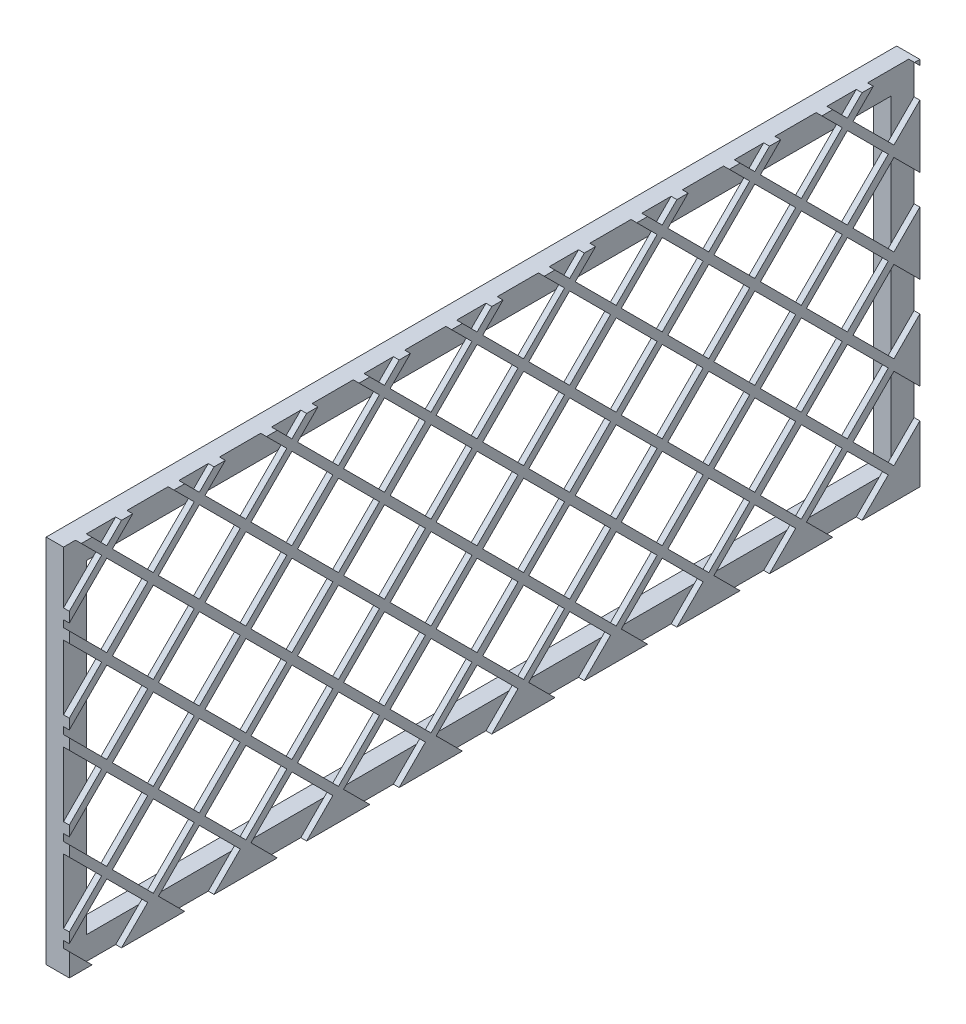
from build123d import *

# Parameters (mm, degrees)
SKETCH1_W           = 466.725
SKETCH1_H           = 203.2
SKETCH1_W_2         = 441.325
SKETCH1_H_2         = 177.8
BOSS_EXTRUDE1_DEPTH = 12.7
SKETCH2_W           = 441.325
SKETCH2_H           = 177.8
BOSS_EXTRUDE2_DEPTH = 3.175
CUT_EXTRUDE1_DEPTH  = 3.175


with BuildPart() as part:
    # Sketch1 → Boss-Extrude1 (new body)
    with BuildSketch(Plane(origin=(0, 0, 0), x_dir=(0, 0, -1), z_dir=(1, 0, 0))):
        with Locations((134.9375, -104.913043478)):
            Rectangle(SKETCH1_W, SKETCH1_H)
        with Locations((134.9375, -104.913043478)):
            Rectangle(SKETCH1_W_2, SKETCH1_H_2, mode=Mode.SUBTRACT)
    extrude(amount=BOSS_EXTRUDE1_DEPTH)

    # Sketch2 → Boss-Extrude2 (add)
    with BuildSketch(Plane(origin=(12.7, 0, 0), x_dir=(0, 0, -1), z_dir=(1, 0, 0))):
        with Locations((134.9375, -104.913043478)):
            Rectangle(SKETCH2_W, SKETCH2_H)
    extrude(amount=-BOSS_EXTRUDE2_DEPTH)

    # Sketch3 → Cut-Extrude1 (cut)
    with BuildSketch(Plane.ZY.offset(-9.525)):
        Polygon((-350.98474355, 163.475506724), (-328.534103247, 185.926147027), (-306.083462944, 163.475506724), (-328.534103247, 141.024866421), align=None)
        Polygon((-354.077856822, 211.182393452), (-331.627216519, 188.731753149), (-354.077856822, 166.281112846), (-376.528497125, 188.731753149), align=None)
        Polygon((-300.18474355, 163.475506724), (-277.734103247, 185.926147027), (-255.283462944, 163.475506724), (-277.734103247, 141.024866421), align=None)
        Polygon((-280.827216519, 188.731753149), (-303.277856822, 166.281112846), (-325.728497125, 188.731753149), (-303.277856822, 211.182393452), align=None)
        Polygon((-249.38474355, 163.475506724), (-226.934103247, 185.926147027), (-204.483462944, 163.475506724), (-226.934103247, 141.024866421), align=None)
        Polygon((-230.027216519, 188.731753149), (-252.477856822, 166.281112846), (-274.928497125, 188.731753149), (-252.477856822, 211.182393452), align=None)
        Polygon((-198.58474355, 163.475506724), (-176.134103247, 185.926147027), (-153.683462944, 163.475506724), (-176.134103247, 141.024866421), align=None)
        Polygon((-179.227216519, 188.731753149), (-201.677856822, 166.281112846), (-224.128497125, 188.731753149), (-201.677856822, 211.182393452), align=None)
        Polygon((-147.78474355, 163.475506724), (-125.334103247, 185.926147027), (-102.883462944, 163.475506724), (-125.334103247, 141.024866421), align=None)
        Polygon((-128.427216519, 188.731753149), (-150.877856822, 166.281112846), (-173.328497125, 188.731753149), (-150.877856822, 211.182393452), align=None)
        Polygon((-96.98474355, 163.475506724), (-74.534103247, 185.926147027), (-52.083462944, 163.475506724), (-74.534103247, 141.024866421), align=None)
        Polygon((-77.627216519, 188.731753149), (-100.077856822, 166.281112846), (-122.528497125, 188.731753149), (-100.077856822, 211.182393452), align=None)
        Polygon((-46.18474355, 163.475506724), (-23.734103247, 185.926147027), (-1.283462944, 163.475506724), (-23.734103247, 141.024866421), align=None)
        Polygon((-26.827216519, 188.731753149), (-49.277856822, 166.281112846), (-71.728497125, 188.731753149), (-49.277856822, 211.182393452), align=None)
        Polygon((4.61525645, 163.475506724), (27.065896753, 185.926147027), (49.516537056, 163.475506724), (27.065896753, 141.024866421), align=None)
        Polygon((23.972783481, 188.731753149), (1.522143178, 166.281112846), (-20.928497125, 188.731753149), (1.522143178, 211.182393452), align=None)
        Polygon((55.41525645, 163.475506724), (77.865896753, 185.926147027), (100.316537056, 163.475506724), (77.865896753, 141.024866421), align=None)
        Polygon((74.772783481, 188.731753149), (52.322143178, 166.281112846), (29.871502875, 188.731753149), (52.322143178, 211.182393452), align=None)
        Polygon((106.21525645, 163.475506724), (128.665896753, 185.926147027), (151.116537056, 163.475506724), (128.665896753, 141.024866421), align=None)
        Polygon((125.572783481, 188.731753149), (103.122143178, 166.281112846), (80.671502875, 188.731753149), (103.122143178, 211.182393452), align=None)
        Polygon((157.01525645, 163.475506724), (179.465896753, 185.926147027), (201.916537056, 163.475506724), (179.465896753, 141.024866421), align=None)
        Polygon((176.372783481, 188.731753149), (153.922143178, 166.281112846), (131.471502875, 188.731753149), (153.922143178, 211.182393452), align=None)
        Polygon((207.81525645, 163.475506724), (230.265896753, 185.926147027), (252.716537056, 163.475506724), (230.265896753, 141.024866421), align=None)
        Polygon((227.172783481, 188.731753149), (204.722143178, 166.281112846), (182.271502875, 188.731753149), (204.722143178, 211.182393452), align=None)
        Polygon((258.61525645, 163.475506724), (281.065896753, 185.926147027), (303.516537056, 163.475506724), (281.065896753, 141.024866421), align=None)
        Polygon((277.972783481, 188.731753149), (255.522143178, 166.281112846), (233.071502875, 188.731753149), (255.522143178, 211.182393452), align=None)
        Polygon((-300.18474355, 112.675506724), (-277.734103247, 135.126147027), (-255.283462944, 112.675506724), (-277.734103247, 90.224866421), align=None)
        Polygon((-280.827216519, 137.931753149), (-303.277856822, 115.481112846), (-325.728497125, 137.931753149), (-303.277856822, 160.382393452), align=None)
        Polygon((-249.38474355, 112.675506724), (-226.934103247, 135.126147027), (-204.483462944, 112.675506724), (-226.934103247, 90.224866421), align=None)
        Polygon((-230.027216519, 137.931753149), (-252.477856822, 115.481112846), (-274.928497125, 137.931753149), (-252.477856822, 160.382393452), align=None)
        Polygon((-198.58474355, 112.675506724), (-176.134103247, 135.126147027), (-153.683462944, 112.675506724), (-176.134103247, 90.224866421), align=None)
        Polygon((-179.227216519, 137.931753149), (-201.677856822, 115.481112846), (-224.128497125, 137.931753149), (-201.677856822, 160.382393452), align=None)
        Polygon((-147.78474355, 112.675506724), (-125.334103247, 135.126147027), (-102.883462944, 112.675506724), (-125.334103247, 90.224866421), align=None)
        Polygon((-128.427216519, 137.931753149), (-150.877856822, 115.481112846), (-173.328497125, 137.931753149), (-150.877856822, 160.382393452), align=None)
        Polygon((-96.98474355, 112.675506724), (-74.534103247, 135.126147027), (-52.083462944, 112.675506724), (-74.534103247, 90.224866421), align=None)
        Polygon((-77.627216519, 137.931753149), (-100.077856822, 115.481112846), (-122.528497125, 137.931753149), (-100.077856822, 160.382393452), align=None)
        Polygon((-46.18474355, 112.675506724), (-23.734103247, 135.126147027), (-1.283462944, 112.675506724), (-23.734103247, 90.224866421), align=None)
        Polygon((-26.827216519, 137.931753149), (-49.277856822, 115.481112846), (-71.728497125, 137.931753149), (-49.277856822, 160.382393452), align=None)
        Polygon((4.61525645, 112.675506724), (27.065896753, 135.126147027), (49.516537056, 112.675506724), (27.065896753, 90.224866421), align=None)
        Polygon((23.972783481, 137.931753149), (1.522143178, 115.481112846), (-20.928497125, 137.931753149), (1.522143178, 160.382393452), align=None)
        Polygon((55.41525645, 112.675506724), (77.865896753, 135.126147027), (100.316537056, 112.675506724), (77.865896753, 90.224866421), align=None)
        Polygon((74.772783481, 137.931753149), (52.322143178, 115.481112846), (29.871502875, 137.931753149), (52.322143178, 160.382393452), align=None)
        Polygon((106.21525645, 112.675506724), (128.665896753, 135.126147027), (151.116537056, 112.675506724), (128.665896753, 90.224866421), align=None)
        Polygon((125.572783481, 137.931753149), (103.122143178, 115.481112846), (80.671502875, 137.931753149), (103.122143178, 160.382393452), align=None)
        Polygon((157.01525645, 112.675506724), (179.465896753, 135.126147027), (201.916537056, 112.675506724), (179.465896753, 90.224866421), align=None)
        Polygon((176.372783481, 137.931753149), (153.922143178, 115.481112846), (131.471502875, 137.931753149), (153.922143178, 160.382393452), align=None)
        Polygon((207.81525645, 112.675506724), (230.265896753, 135.126147027), (252.716537056, 112.675506724), (230.265896753, 90.224866421), align=None)
        Polygon((227.172783481, 137.931753149), (204.722143178, 115.481112846), (182.271502875, 137.931753149), (204.722143178, 160.382393452), align=None)
        Polygon((258.61525645, 112.675506724), (281.065896753, 135.126147027), (303.516537056, 112.675506724), (281.065896753, 90.224866421), align=None)
        Polygon((277.972783481, 137.931753149), (255.522143178, 115.481112846), (233.071502875, 137.931753149), (255.522143178, 160.382393452), align=None)
        Polygon((-300.18474355, 61.875506724), (-277.734103247, 84.326147027), (-255.283462944, 61.875506724), (-277.734103247, 39.424866421), align=None)
        Polygon((-280.827216519, 87.131753149), (-303.277856822, 64.681112846), (-325.728497125, 87.131753149), (-303.277856822, 109.582393452), align=None)
        Polygon((-249.38474355, 61.875506724), (-226.934103247, 84.326147027), (-204.483462944, 61.875506724), (-226.934103247, 39.424866421), align=None)
        Polygon((-230.027216519, 87.131753149), (-252.477856822, 64.681112846), (-274.928497125, 87.131753149), (-252.477856822, 109.582393452), align=None)
        Polygon((-198.58474355, 61.875506724), (-176.134103247, 84.326147027), (-153.683462944, 61.875506724), (-176.134103247, 39.424866421), align=None)
        Polygon((-179.227216519, 87.131753149), (-201.677856822, 64.681112846), (-224.128497125, 87.131753149), (-201.677856822, 109.582393452), align=None)
        Polygon((-147.78474355, 61.875506724), (-125.334103247, 84.326147027), (-102.883462944, 61.875506724), (-125.334103247, 39.424866421), align=None)
        Polygon((-128.427216519, 87.131753149), (-150.877856822, 64.681112846), (-173.328497125, 87.131753149), (-150.877856822, 109.582393452), align=None)
        Polygon((-96.98474355, 61.875506724), (-74.534103247, 84.326147027), (-52.083462944, 61.875506724), (-74.534103247, 39.424866421), align=None)
        Polygon((-77.627216519, 87.131753149), (-100.077856822, 64.681112846), (-122.528497125, 87.131753149), (-100.077856822, 109.582393452), align=None)
        Polygon((-46.18474355, 61.875506724), (-23.734103247, 84.326147027), (-1.283462944, 61.875506724), (-23.734103247, 39.424866421), align=None)
        Polygon((-26.827216519, 87.131753149), (-49.277856822, 64.681112846), (-71.728497125, 87.131753149), (-49.277856822, 109.582393452), align=None)
        Polygon((4.61525645, 61.875506724), (27.065896753, 84.326147027), (49.516537056, 61.875506724), (27.065896753, 39.424866421), align=None)
        Polygon((23.972783481, 87.131753149), (1.522143178, 64.681112846), (-20.928497125, 87.131753149), (1.522143178, 109.582393452), align=None)
        Polygon((55.41525645, 61.875506724), (77.865896753, 84.326147027), (100.316537056, 61.875506724), (77.865896753, 39.424866421), align=None)
        Polygon((74.772783481, 87.131753149), (52.322143178, 64.681112846), (29.871502875, 87.131753149), (52.322143178, 109.582393452), align=None)
        Polygon((106.21525645, 61.875506724), (128.665896753, 84.326147027), (151.116537056, 61.875506724), (128.665896753, 39.424866421), align=None)
        Polygon((125.572783481, 87.131753149), (103.122143178, 64.681112846), (80.671502875, 87.131753149), (103.122143178, 109.582393452), align=None)
        Polygon((157.01525645, 61.875506724), (179.465896753, 84.326147027), (201.916537056, 61.875506724), (179.465896753, 39.424866421), align=None)
        Polygon((176.372783481, 87.131753149), (153.922143178, 64.681112846), (131.471502875, 87.131753149), (153.922143178, 109.582393452), align=None)
        Polygon((207.81525645, 61.875506724), (230.265896753, 84.326147027), (252.716537056, 61.875506724), (230.265896753, 39.424866421), align=None)
        Polygon((227.172783481, 87.131753149), (204.722143178, 64.681112846), (182.271502875, 87.131753149), (204.722143178, 109.582393452), align=None)
        Polygon((258.61525645, 61.875506724), (281.065896753, 84.326147027), (303.516537056, 61.875506724), (281.065896753, 39.424866421), align=None)
        Polygon((277.972783481, 87.131753149), (255.522143178, 64.681112846), (233.071502875, 87.131753149), (255.522143178, 109.582393452), align=None)
        Polygon((-300.18474355, 11.075506724), (-277.734103247, 33.526147027), (-255.283462944, 11.075506724), (-277.734103247, -11.375133579), align=None)
        Polygon((-280.827216519, 36.331753149), (-303.277856822, 13.881112846), (-325.728497125, 36.331753149), (-303.277856822, 58.782393452), align=None)
        Polygon((-249.38474355, 11.075506724), (-226.934103247, 33.526147027), (-204.483462944, 11.075506724), (-226.934103247, -11.375133579), align=None)
        Polygon((-230.027216519, 36.331753149), (-252.477856822, 13.881112846), (-274.928497125, 36.331753149), (-252.477856822, 58.782393452), align=None)
        Polygon((-198.58474355, 11.075506724), (-176.134103247, 33.526147027), (-153.683462944, 11.075506724), (-176.134103247, -11.375133579), align=None)
        Polygon((-179.227216519, 36.331753149), (-201.677856822, 13.881112846), (-224.128497125, 36.331753149), (-201.677856822, 58.782393452), align=None)
        Polygon((-147.78474355, 11.075506724), (-125.334103247, 33.526147027), (-102.883462944, 11.075506724), (-125.334103247, -11.375133579), align=None)
        Polygon((-128.427216519, 36.331753149), (-150.877856822, 13.881112846), (-173.328497125, 36.331753149), (-150.877856822, 58.782393452), align=None)
        Polygon((-96.98474355, 11.075506724), (-74.534103247, 33.526147027), (-52.083462944, 11.075506724), (-74.534103247, -11.375133579), align=None)
        Polygon((-77.627216519, 36.331753149), (-100.077856822, 13.881112846), (-122.528497125, 36.331753149), (-100.077856822, 58.782393452), align=None)
        Polygon((-46.18474355, 11.075506724), (-23.734103247, 33.526147027), (-1.283462944, 11.075506724), (-23.734103247, -11.375133579), align=None)
        Polygon((-26.827216519, 36.331753149), (-49.277856822, 13.881112846), (-71.728497125, 36.331753149), (-49.277856822, 58.782393452), align=None)
        Polygon((4.61525645, 11.075506724), (27.065896753, 33.526147027), (49.516537056, 11.075506724), (27.065896753, -11.375133579), align=None)
        Polygon((23.972783481, 36.331753149), (1.522143178, 13.881112846), (-20.928497125, 36.331753149), (1.522143178, 58.782393452), align=None)
        Polygon((55.41525645, 11.075506724), (77.865896753, 33.526147027), (100.316537056, 11.075506724), (77.865896753, -11.375133579), align=None)
        Polygon((74.772783481, 36.331753149), (52.322143178, 13.881112846), (29.871502875, 36.331753149), (52.322143178, 58.782393452), align=None)
        Polygon((106.21525645, 11.075506724), (128.665896753, 33.526147027), (151.116537056, 11.075506724), (128.665896753, -11.375133579), align=None)
        Polygon((125.572783481, 36.331753149), (103.122143178, 13.881112846), (80.671502875, 36.331753149), (103.122143178, 58.782393452), align=None)
        Polygon((157.01525645, 11.075506724), (179.465896753, 33.526147027), (201.916537056, 11.075506724), (179.465896753, -11.375133579), align=None)
        Polygon((176.372783481, 36.331753149), (153.922143178, 13.881112846), (131.471502875, 36.331753149), (153.922143178, 58.782393452), align=None)
        Polygon((207.81525645, 11.075506724), (230.265896753, 33.526147027), (252.716537056, 11.075506724), (230.265896753, -11.375133579), align=None)
        Polygon((227.172783481, 36.331753149), (204.722143178, 13.881112846), (182.271502875, 36.331753149), (204.722143178, 58.782393452), align=None)
        Polygon((258.61525645, 11.075506724), (281.065896753, 33.526147027), (303.516537056, 11.075506724), (281.065896753, -11.375133579), align=None)
        Polygon((277.972783481, 36.331753149), (255.522143178, 13.881112846), (233.071502875, 36.331753149), (255.522143178, 58.782393452), align=None)
        Polygon((-300.18474355, -39.724493276), (-277.734103247, -17.273852973), (-255.283462944, -39.724493276), (-277.734103247, -62.175133579), align=None)
        Polygon((-280.827216519, -14.468246851), (-303.277856822, -36.918887154), (-325.728497125, -14.468246851), (-303.277856822, 7.982393452), align=None)
        Polygon((-249.38474355, -39.724493276), (-226.934103247, -17.273852973), (-204.483462944, -39.724493276), (-226.934103247, -62.175133579), align=None)
        Polygon((-230.027216519, -14.468246851), (-252.477856822, -36.918887154), (-274.928497125, -14.468246851), (-252.477856822, 7.982393452), align=None)
        Polygon((-198.58474355, -39.724493276), (-176.134103247, -17.273852973), (-153.683462944, -39.724493276), (-176.134103247, -62.175133579), align=None)
        Polygon((-179.227216519, -14.468246851), (-201.677856822, -36.918887154), (-224.128497125, -14.468246851), (-201.677856822, 7.982393452), align=None)
        Polygon((-147.78474355, -39.724493276), (-125.334103247, -17.273852973), (-102.883462944, -39.724493276), (-125.334103247, -62.175133579), align=None)
        Polygon((-128.427216519, -14.468246851), (-150.877856822, -36.918887154), (-173.328497125, -14.468246851), (-150.877856822, 7.982393452), align=None)
        Polygon((-96.98474355, -39.724493276), (-74.534103247, -17.273852973), (-52.083462944, -39.724493276), (-74.534103247, -62.175133579), align=None)
        Polygon((-77.627216519, -14.468246851), (-100.077856822, -36.918887154), (-122.528497125, -14.468246851), (-100.077856822, 7.982393452), align=None)
        Polygon((-46.18474355, -39.724493276), (-23.734103247, -17.273852973), (-1.283462944, -39.724493276), (-23.734103247, -62.175133579), align=None)
        Polygon((-26.827216519, -14.468246851), (-49.277856822, -36.918887154), (-71.728497125, -14.468246851), (-49.277856822, 7.982393452), align=None)
        Polygon((4.61525645, -39.724493276), (27.065896753, -17.273852973), (49.516537056, -39.724493276), (27.065896753, -62.175133579), align=None)
        Polygon((23.972783481, -14.468246851), (1.522143178, -36.918887154), (-20.928497125, -14.468246851), (1.522143178, 7.982393452), align=None)
        Polygon((55.41525645, -39.724493276), (77.865896753, -17.273852973), (100.316537056, -39.724493276), (77.865896753, -62.175133579), align=None)
        Polygon((74.772783481, -14.468246851), (52.322143178, -36.918887154), (29.871502875, -14.468246851), (52.322143178, 7.982393452), align=None)
        Polygon((106.21525645, -39.724493276), (128.665896753, -17.273852973), (151.116537056, -39.724493276), (128.665896753, -62.175133579), align=None)
        Polygon((125.572783481, -14.468246851), (103.122143178, -36.918887154), (80.671502875, -14.468246851), (103.122143178, 7.982393452), align=None)
        Polygon((157.01525645, -39.724493276), (179.465896753, -17.273852973), (201.916537056, -39.724493276), (179.465896753, -62.175133579), align=None)
        Polygon((176.372783481, -14.468246851), (153.922143178, -36.918887154), (131.471502875, -14.468246851), (153.922143178, 7.982393452), align=None)
        Polygon((207.81525645, -39.724493276), (230.265896753, -17.273852973), (252.716537056, -39.724493276), (230.265896753, -62.175133579), align=None)
        Polygon((227.172783481, -14.468246851), (204.722143178, -36.918887154), (182.271502875, -14.468246851), (204.722143178, 7.982393452), align=None)
        Polygon((258.61525645, -39.724493276), (281.065896753, -17.273852973), (303.516537056, -39.724493276), (281.065896753, -62.175133579), align=None)
        Polygon((277.972783481, -14.468246851), (255.522143178, -36.918887154), (233.071502875, -14.468246851), (255.522143178, 7.982393452), align=None)
        Polygon((-300.18474355, -90.524493276), (-277.734103247, -68.073852973), (-255.283462944, -90.524493276), (-277.734103247, -112.975133579), align=None)
        Polygon((-280.827216519, -65.268246851), (-303.277856822, -87.718887154), (-325.728497125, -65.268246851), (-303.277856822, -42.817606548), align=None)
        Polygon((-249.38474355, -90.524493276), (-226.934103247, -68.073852973), (-204.483462944, -90.524493276), (-226.934103247, -112.975133579), align=None)
        Polygon((-230.027216519, -65.268246851), (-252.477856822, -87.718887154), (-274.928497125, -65.268246851), (-252.477856822, -42.817606548), align=None)
        Polygon((-198.58474355, -90.524493276), (-176.134103247, -68.073852973), (-153.683462944, -90.524493276), (-176.134103247, -112.975133579), align=None)
        Polygon((-179.227216519, -65.268246851), (-201.677856822, -87.718887154), (-224.128497125, -65.268246851), (-201.677856822, -42.817606548), align=None)
        Polygon((-147.78474355, -90.524493276), (-125.334103247, -68.073852973), (-102.883462944, -90.524493276), (-125.334103247, -112.975133579), align=None)
        Polygon((-128.427216519, -65.268246851), (-150.877856822, -87.718887154), (-173.328497125, -65.268246851), (-150.877856822, -42.817606548), align=None)
        Polygon((-96.98474355, -90.524493276), (-74.534103247, -68.073852973), (-52.083462944, -90.524493276), (-74.534103247, -112.975133579), align=None)
        Polygon((-77.627216519, -65.268246851), (-100.077856822, -87.718887154), (-122.528497125, -65.268246851), (-100.077856822, -42.817606548), align=None)
        Polygon((-46.18474355, -90.524493276), (-23.734103247, -68.073852973), (-1.283462944, -90.524493276), (-23.734103247, -112.975133579), align=None)
        Polygon((-26.827216519, -65.268246851), (-49.277856822, -87.718887154), (-71.728497125, -65.268246851), (-49.277856822, -42.817606548), align=None)
        Polygon((4.61525645, -90.524493276), (27.065896753, -68.073852973), (49.516537056, -90.524493276), (27.065896753, -112.975133579), align=None)
        Polygon((23.972783481, -65.268246851), (1.522143178, -87.718887154), (-20.928497125, -65.268246851), (1.522143178, -42.817606548), align=None)
        Polygon((55.41525645, -90.524493276), (77.865896753, -68.073852973), (100.316537056, -90.524493276), (77.865896753, -112.975133579), align=None)
        Polygon((74.772783481, -65.268246851), (52.322143178, -87.718887154), (29.871502875, -65.268246851), (52.322143178, -42.817606548), align=None)
        Polygon((106.21525645, -90.524493276), (128.665896753, -68.073852973), (151.116537056, -90.524493276), (128.665896753, -112.975133579), align=None)
        Polygon((125.572783481, -65.268246851), (103.122143178, -87.718887154), (80.671502875, -65.268246851), (103.122143178, -42.817606548), align=None)
        Polygon((157.01525645, -90.524493276), (179.465896753, -68.073852973), (201.916537056, -90.524493276), (179.465896753, -112.975133579), align=None)
        Polygon((176.372783481, -65.268246851), (153.922143178, -87.718887154), (131.471502875, -65.268246851), (153.922143178, -42.817606548), align=None)
        Polygon((207.81525645, -90.524493276), (230.265896753, -68.073852973), (252.716537056, -90.524493276), (230.265896753, -112.975133579), align=None)
        Polygon((227.172783481, -65.268246851), (204.722143178, -87.718887154), (182.271502875, -65.268246851), (204.722143178, -42.817606548), align=None)
        Polygon((258.61525645, -90.524493276), (281.065896753, -68.073852973), (303.516537056, -90.524493276), (281.065896753, -112.975133579), align=None)
        Polygon((277.972783481, -65.268246851), (255.522143178, -87.718887154), (233.071502875, -65.268246851), (255.522143178, -42.817606548), align=None)
        Polygon((-300.18474355, -141.324493276), (-277.734103247, -118.873852973), (-255.283462944, -141.324493276), (-277.734103247, -163.775133579), align=None)
        Polygon((-280.827216519, -116.068246851), (-303.277856822, -138.518887154), (-325.728497125, -116.068246851), (-303.277856822, -93.617606548), align=None)
        Polygon((-249.38474355, -141.324493276), (-226.934103247, -118.873852973), (-204.483462944, -141.324493276), (-226.934103247, -163.775133579), align=None)
        Polygon((-230.027216519, -116.068246851), (-252.477856822, -138.518887154), (-274.928497125, -116.068246851), (-252.477856822, -93.617606548), align=None)
        Polygon((-198.58474355, -141.324493276), (-176.134103247, -118.873852973), (-153.683462944, -141.324493276), (-176.134103247, -163.775133579), align=None)
        Polygon((-179.227216519, -116.068246851), (-201.677856822, -138.518887154), (-224.128497125, -116.068246851), (-201.677856822, -93.617606548), align=None)
        Polygon((-147.78474355, -141.324493276), (-125.334103247, -118.873852973), (-102.883462944, -141.324493276), (-125.334103247, -163.775133579), align=None)
        Polygon((-128.427216519, -116.068246851), (-150.877856822, -138.518887154), (-173.328497125, -116.068246851), (-150.877856822, -93.617606548), align=None)
        Polygon((-96.98474355, -141.324493276), (-74.534103247, -118.873852973), (-52.083462944, -141.324493276), (-74.534103247, -163.775133579), align=None)
        Polygon((-77.627216519, -116.068246851), (-100.077856822, -138.518887154), (-122.528497125, -116.068246851), (-100.077856822, -93.617606548), align=None)
        Polygon((-46.18474355, -141.324493276), (-23.734103247, -118.873852973), (-1.283462944, -141.324493276), (-23.734103247, -163.775133579), align=None)
        Polygon((-26.827216519, -116.068246851), (-49.277856822, -138.518887154), (-71.728497125, -116.068246851), (-49.277856822, -93.617606548), align=None)
        Polygon((4.61525645, -141.324493276), (27.065896753, -118.873852973), (49.516537056, -141.324493276), (27.065896753, -163.775133579), align=None)
        Polygon((23.972783481, -116.068246851), (1.522143178, -138.518887154), (-20.928497125, -116.068246851), (1.522143178, -93.617606548), align=None)
        Polygon((55.41525645, -141.324493276), (77.865896753, -118.873852973), (100.316537056, -141.324493276), (77.865896753, -163.775133579), align=None)
        Polygon((74.772783481, -116.068246851), (52.322143178, -138.518887154), (29.871502875, -116.068246851), (52.322143178, -93.617606548), align=None)
        Polygon((106.21525645, -141.324493276), (128.665896753, -118.873852973), (151.116537056, -141.324493276), (128.665896753, -163.775133579), align=None)
        Polygon((125.572783481, -116.068246851), (103.122143178, -138.518887154), (80.671502875, -116.068246851), (103.122143178, -93.617606548), align=None)
        Polygon((157.01525645, -141.324493276), (179.465896753, -118.873852973), (201.916537056, -141.324493276), (179.465896753, -163.775133579), align=None)
        Polygon((176.372783481, -116.068246851), (153.922143178, -138.518887154), (131.471502875, -116.068246851), (153.922143178, -93.617606548), align=None)
        Polygon((207.81525645, -141.324493276), (230.265896753, -118.873852973), (252.716537056, -141.324493276), (230.265896753, -163.775133579), align=None)
        Polygon((227.172783481, -116.068246851), (204.722143178, -138.518887154), (182.271502875, -116.068246851), (204.722143178, -93.617606548), align=None)
        Polygon((258.61525645, -141.324493276), (281.065896753, -118.873852973), (303.516537056, -141.324493276), (281.065896753, -163.775133579), align=None)
        Polygon((277.972783481, -116.068246851), (255.522143178, -138.518887154), (233.071502875, -116.068246851), (255.522143178, -93.617606548), align=None)
        Polygon((-300.18474355, -192.124493276), (-277.734103247, -169.673852973), (-255.283462944, -192.124493276), (-277.734103247, -214.575133579), align=None)
        Polygon((-280.827216519, -166.868246851), (-303.277856822, -189.318887154), (-325.728497125, -166.868246851), (-303.277856822, -144.417606548), align=None)
        Polygon((-249.38474355, -192.124493276), (-226.934103247, -169.673852973), (-204.483462944, -192.124493276), (-226.934103247, -214.575133579), align=None)
        Polygon((-230.027216519, -166.868246851), (-252.477856822, -189.318887154), (-274.928497125, -166.868246851), (-252.477856822, -144.417606548), align=None)
        Polygon((-198.58474355, -192.124493276), (-176.134103247, -169.673852973), (-153.683462944, -192.124493276), (-176.134103247, -214.575133579), align=None)
        Polygon((-179.227216519, -166.868246851), (-201.677856822, -189.318887154), (-224.128497125, -166.868246851), (-201.677856822, -144.417606548), align=None)
        Polygon((-147.78474355, -192.124493276), (-125.334103247, -169.673852973), (-102.883462944, -192.124493276), (-125.334103247, -214.575133579), align=None)
        Polygon((-128.427216519, -166.868246851), (-150.877856822, -189.318887154), (-173.328497125, -166.868246851), (-150.877856822, -144.417606548), align=None)
        Polygon((-96.98474355, -192.124493276), (-74.534103247, -169.673852973), (-52.083462944, -192.124493276), (-74.534103247, -214.575133579), align=None)
        Polygon((-77.627216519, -166.868246851), (-100.077856822, -189.318887154), (-122.528497125, -166.868246851), (-100.077856822, -144.417606548), align=None)
        Polygon((-46.18474355, -192.124493276), (-23.734103247, -169.673852973), (-1.283462944, -192.124493276), (-23.734103247, -214.575133579), align=None)
        Polygon((-26.827216519, -166.868246851), (-49.277856822, -189.318887154), (-71.728497125, -166.868246851), (-49.277856822, -144.417606548), align=None)
        Polygon((4.61525645, -192.124493276), (27.065896753, -169.673852973), (49.516537056, -192.124493276), (27.065896753, -214.575133579), align=None)
        Polygon((23.972783481, -166.868246851), (1.522143178, -189.318887154), (-20.928497125, -166.868246851), (1.522143178, -144.417606548), align=None)
        Polygon((55.41525645, -192.124493276), (77.865896753, -169.673852973), (100.316537056, -192.124493276), (77.865896753, -214.575133579), align=None)
        Polygon((74.772783481, -166.868246851), (52.322143178, -189.318887154), (29.871502875, -166.868246851), (52.322143178, -144.417606548), align=None)
        Polygon((106.21525645, -192.124493276), (128.665896753, -169.673852973), (151.116537056, -192.124493276), (128.665896753, -214.575133579), align=None)
        Polygon((125.572783481, -166.868246851), (103.122143178, -189.318887154), (80.671502875, -166.868246851), (103.122143178, -144.417606548), align=None)
        Polygon((157.01525645, -192.124493276), (179.465896753, -169.673852973), (201.916537056, -192.124493276), (179.465896753, -214.575133579), align=None)
        Polygon((176.372783481, -166.868246851), (153.922143178, -189.318887154), (131.471502875, -166.868246851), (153.922143178, -144.417606548), align=None)
        Polygon((207.81525645, -192.124493276), (230.265896753, -169.673852973), (252.716537056, -192.124493276), (230.265896753, -214.575133579), align=None)
        Polygon((227.172783481, -166.868246851), (204.722143178, -189.318887154), (182.271502875, -166.868246851), (204.722143178, -144.417606548), align=None)
        Polygon((258.61525645, -192.124493276), (281.065896753, -169.673852973), (303.516537056, -192.124493276), (281.065896753, -214.575133579), align=None)
        Polygon((277.972783481, -166.868246851), (255.522143178, -189.318887154), (233.071502875, -166.868246851), (255.522143178, -144.417606548), align=None)
        Polygon((-350.98474355, 112.675506724), (-328.534103247, 135.126147027), (-306.083462944, 112.675506724), (-328.534103247, 90.224866421), align=None)
        Polygon((-331.627216519, 137.931753149), (-354.077856822, 115.481112846), (-376.528497125, 137.931753149), (-354.077856822, 160.382393452), align=None)
        Polygon((-350.98474355, 61.875506724), (-328.534103247, 84.326147027), (-306.083462944, 61.875506724), (-328.534103247, 39.424866421), align=None)
        Polygon((-331.627216519, 87.131753149), (-354.077856822, 64.681112846), (-376.528497125, 87.131753149), (-354.077856822, 109.582393452), align=None)
        Polygon((-350.98474355, 11.075506724), (-328.534103247, 33.526147027), (-306.083462944, 11.075506724), (-328.534103247, -11.375133579), align=None)
        Polygon((-331.627216519, 36.331753149), (-354.077856822, 13.881112846), (-376.528497125, 36.331753149), (-354.077856822, 58.782393452), align=None)
        Polygon((-350.98474355, -39.724493276), (-328.534103247, -17.273852973), (-306.083462944, -39.724493276), (-328.534103247, -62.175133579), align=None)
        Polygon((-331.627216519, -14.468246851), (-354.077856822, -36.918887154), (-376.528497125, -14.468246851), (-354.077856822, 7.982393452), align=None)
        Polygon((-350.98474355, -90.524493276), (-328.534103247, -68.073852973), (-306.083462944, -90.524493276), (-328.534103247, -112.975133579), align=None)
        Polygon((-331.627216519, -65.268246851), (-354.077856822, -87.718887154), (-376.528497125, -65.268246851), (-354.077856822, -42.817606548), align=None)
        Polygon((-350.98474355, -141.324493276), (-328.534103247, -118.873852973), (-306.083462944, -141.324493276), (-328.534103247, -163.775133579), align=None)
        Polygon((-331.627216519, -116.068246851), (-354.077856822, -138.518887154), (-376.528497125, -116.068246851), (-354.077856822, -93.617606548), align=None)
        Polygon((-350.98474355, -192.124493276), (-328.534103247, -169.673852973), (-306.083462944, -192.124493276), (-328.534103247, -214.575133579), align=None)
        Polygon((-331.627216519, -166.868246851), (-354.077856822, -189.318887154), (-376.528497125, -166.868246851), (-354.077856822, -144.417606548), align=None)
    extrude(amount=-CUT_EXTRUDE1_DEPTH, mode=Mode.SUBTRACT)


solid = part.part
